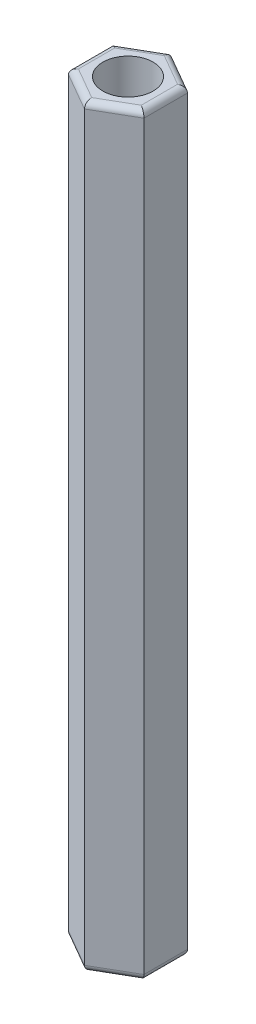
from build123d import *

# Parameters (mm, degrees)
SKETCH_1_R      = 2
EXTRUDE_1_DEPTH = 60
FILLET_1_R      = 0.5


with BuildPart() as part:
    # 草图1 → 凸台-拉伸1 (new body)
    with BuildSketch(Plane(origin=(0, 0, 0), x_dir=(1, 0, 0), z_dir=(0, 1, 0))):
        Polygon((3, -1.732050808), (3, 1.732050808), (0, 3.464101615), (-3, 1.732050808), (-3, -1.732050808), (0, -3.464101615), align=None)
        Circle(SKETCH_1_R, mode=Mode.SUBTRACT)
    extrude(amount=EXTRUDE_1_DEPTH)

    # 圆角1
    fillet_1_edges = [part.edges().sort_by_distance(p)[0] for p in [
        (1.5, 60, -2.598076211),
        (-1.5, 60, -2.598076211),
        (-3, 60, 0),
        (-1.5, 60, 2.598076211),
        (1.5, 60, 2.598076211),
        (-1.5, 0, 2.598076211),
        (-3, 0, 0),
        (-1.5, 0, -2.598076211),
        (1.5, 0, -2.598076211),
        (3, 0, 0),
        (1.5, 0, 2.598076211),
        (3, 60, 0),
    ]]
    fillet(fillet_1_edges, radius=FILLET_1_R)


solid = part.part
